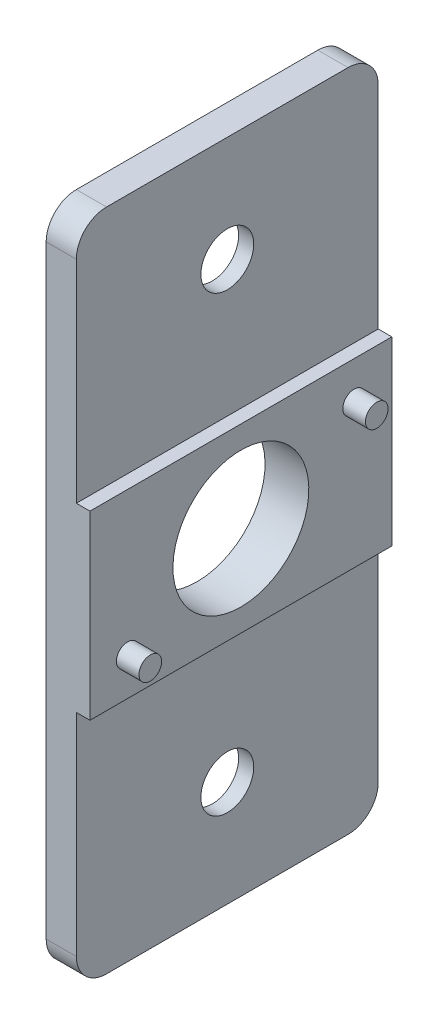
from build123d import *

# Parameters (mm, degrees)
BOSS_EXTRUDE1_DEPTH = 20
SKETCH2_R           = 1.75
SKETCH2_R_2         = 4.5
CUT_EXTRUDE1_DEPTH  = 3.9
SKETCH3_R           = 0.75
BOSS_EXTRUDE2_DEPTH = 1.5
FILLET1_R           = 2
CUT_EXTRUDE2_DEPTH  = 1


with BuildPart() as part:
    # Sketch1 → Boss-Extrude1 (new body)
    with BuildSketch(Plane.XY):
        Polygon((0, 0), (0, -44), (2, -44), (2, -28), (2.9, -28), (2.9, -16), (2, -16), (2, 0), align=None)
    extrude(amount=BOSS_EXTRUDE1_DEPTH)

    # Sketch2 → Cut-Extrude1 (cut, through all)
    with BuildSketch(Plane.ZY):
        with Locations((10, -7)):
            Circle(SKETCH2_R)
        with Locations((10, -37)):
            Circle(SKETCH2_R)
        with Locations((10, -22)):
            Circle(SKETCH2_R_2)
    extrude(amount=-CUT_EXTRUDE1_DEPTH, mode=Mode.SUBTRACT)

    # Sketch3 → Boss-Extrude2 (add)
    with BuildSketch(Plane(origin=(2.9, 0, 0), x_dir=(0, 0, -1), z_dir=(1, 0, 0))):
        with Locations((-17.5, -25.5)):
            Circle(SKETCH3_R)
        with Locations((-2.5, -18.5)):
            Circle(SKETCH3_R)
    extrude(amount=BOSS_EXTRUDE2_DEPTH)

    # Fillet1
    fillet1_edges = [part.edges().sort_by_distance(p)[0] for p in [
        (1, -44, 20),
        (1, 0, 0),
        (1, 0, 20),
        (1, -44, 0),
    ]]
    fillet(fillet1_edges, radius=FILLET1_R)

    # Sketch4 → Cut-Extrude2 (cut)
    with BuildSketch(Plane.ZY):
        Polygon((11.876388375, -10.25), (13.75277675, -7), (11.876388375, -3.75), (8.123611625, -3.75), (6.24722325, -7), (8.123611625, -10.25), align=None)
        Polygon((11.876388375, -40.25), (13.75277675, -37), (11.876388375, -33.75), (8.123611625, -33.75), (6.24722325, -37), (8.123611625, -40.25), align=None)
    extrude(amount=-CUT_EXTRUDE2_DEPTH, mode=Mode.SUBTRACT)


solid = part.part
